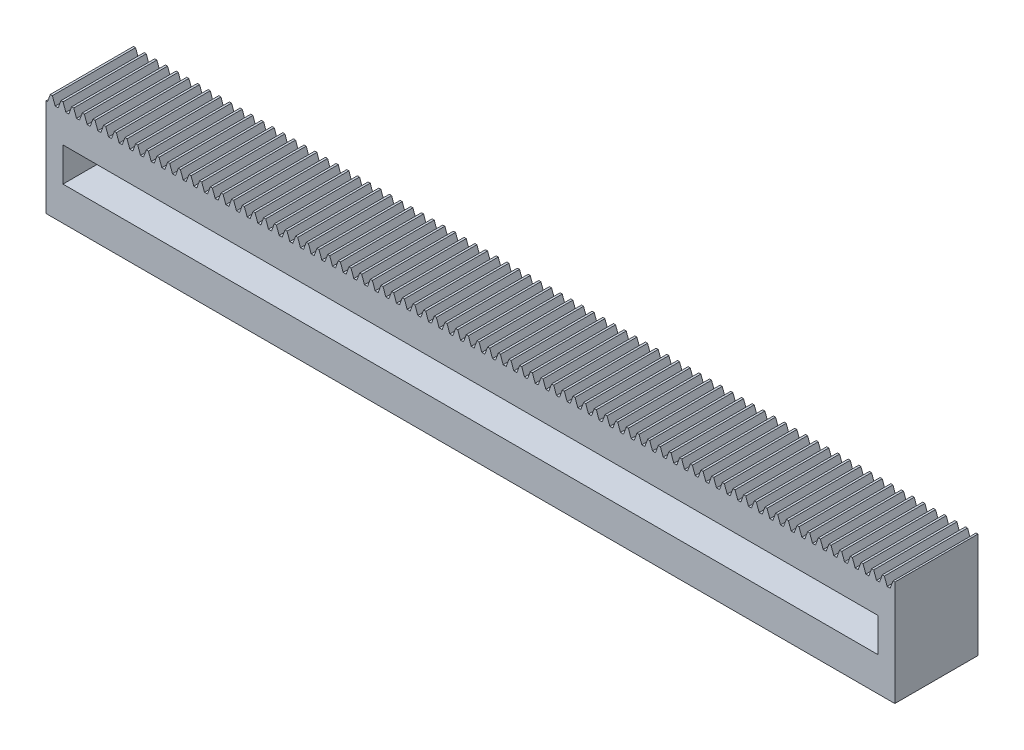
from build123d import *

# Parameters (mm, degrees)
BLANKSKE_W         = 250
BLANKSKE_H         = 31
BLANK_DEPTH        = 24.5
TOOTHCUTSIM_DEPTH  = 254.103239805
TEETHCUTS_COUNT    = 80
TEETHCUTS_PITCH    = 3.14159265
SKETCH1_W          = 240
SKETCH1_H          = 10
CUT_EXTRUDE1_DEPTH = 24.5


with BuildPart() as part:
    # BlankSke → Blank (new body)
    with BuildSketch(Plane.XY):
        with Locations((125, 15.5)):
            Rectangle(BLANKSKE_W, BLANKSKE_H)
    extrude(amount=-BLANK_DEPTH)

    # TooCutSkeSim → ToothCutSim (cut, through all)
    with BuildSketch(Plane.XY):
        Polygon((0.44443537, 28.75), (-0.44443537, 28.75), (-1.272613241, 31.0254), (1.272613241, 31.0254), align=None)
    toothcutsim = extrude(amount=-TOOTHCUTSIM_DEPTH, mode=Mode.SUBTRACT)

    # TeethCuts: ToothCutSim ×80
    with Locations(*[(i * TEETHCUTS_PITCH, 0, 0) for i in range(1, TEETHCUTS_COUNT)]):
        add(toothcutsim, mode=Mode.SUBTRACT)

    # Sketch1 → Cut-Extrude1 (cut)
    with BuildSketch(Plane.XY):
        with Locations((125, 15)):
            Rectangle(SKETCH1_W, SKETCH1_H)
    extrude(amount=-CUT_EXTRUDE1_DEPTH, mode=Mode.SUBTRACT)


solid = part.part
